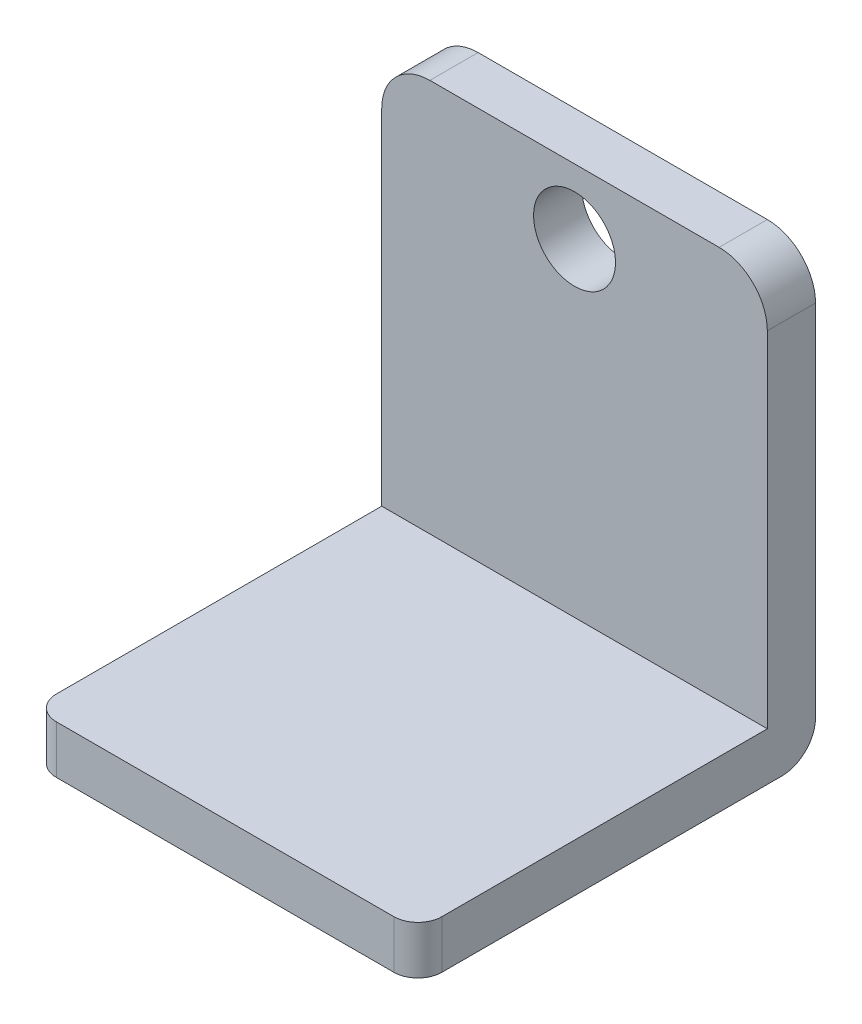
from build123d import *

# Parameters (mm, degrees)
SKETCH1_W           = 203.2
SKETCH1_H           = 209.55
BOSS_EXTRUDE2_DEPTH = 25.4
SKETCH2_W           = 203.2
SKETCH2_H           = 25.4
BOSS_EXTRUDE3_DEPTH = 207.01
CUT_EXTRUDE1_REACH  = 211.55
SKETCH3_R           = 21.59
FILLET1_R           = 17.78
FILLET2_R           = 25.4
FILLET3_R           = 12.7


with BuildPart() as part:
    # Sketch1 → Boss-Extrude2 (new body)
    with BuildSketch(Plane(origin=(0, 0, 0), x_dir=(1, 0, 0), z_dir=(0, 1, 0))):
        with Locations((2.519008264, 3.542355372)):
            Rectangle(SKETCH1_W, SKETCH1_H)
    extrude(amount=BOSS_EXTRUDE2_DEPTH)

    # Sketch2 → Boss-Extrude3 (add)
    with BuildSketch(Plane(origin=(0, 25.4, 0), x_dir=(1, 0, 0), z_dir=(0, 1, 0))):
        with Locations((2.519008264, 95.617355372)):
            Rectangle(SKETCH2_W, SKETCH2_H)
    extrude(amount=BOSS_EXTRUDE3_DEPTH)

    # Sketch3 → Cut-Extrude1 (cut, up to next)
    with BuildSketch(Plane(origin=(0, 0, -108.317355372), x_dir=(-1, 0, 0), z_dir=(0, 0, -1)), mode=Mode.PRIVATE) as cut_extrude1_sk1:
        with Locations((-2.519008264, 198.12)):
            Circle(SKETCH3_R)
    cut_extrude1_tool1 = extrude(cut_extrude1_sk1.sketch, amount=-CUT_EXTRUDE1_REACH, mode=Mode.PRIVATE) & part.part
    add(cut_extrude1_tool1.solids().sort_by_distance((2.519008, 198.12, -108.317355))[0], mode=Mode.SUBTRACT)

    # Fillet1
    fillet1_edges = [part.edges().sort_by_distance(p)[0] for p in [
        (2.519008264, 0, -108.317355372),
    ]]
    fillet(fillet1_edges, radius=FILLET1_R)

    # Fillet2
    fillet2_edges = [part.edges().sort_by_distance(p)[0] for p in [
        (-99.080991736, 232.41, -95.617355372),
        (104.119008264, 232.41, -95.617355372),
    ]]
    fillet(fillet2_edges, radius=FILLET2_R)

    # Fillet3
    fillet3_edges = [part.edges().sort_by_distance(p)[0] for p in [
        (104.119008264, 12.7, 101.232644628),
        (-99.080991736, 12.7, 101.232644628),
    ]]
    fillet(fillet3_edges, radius=FILLET3_R)


solid = part.part
